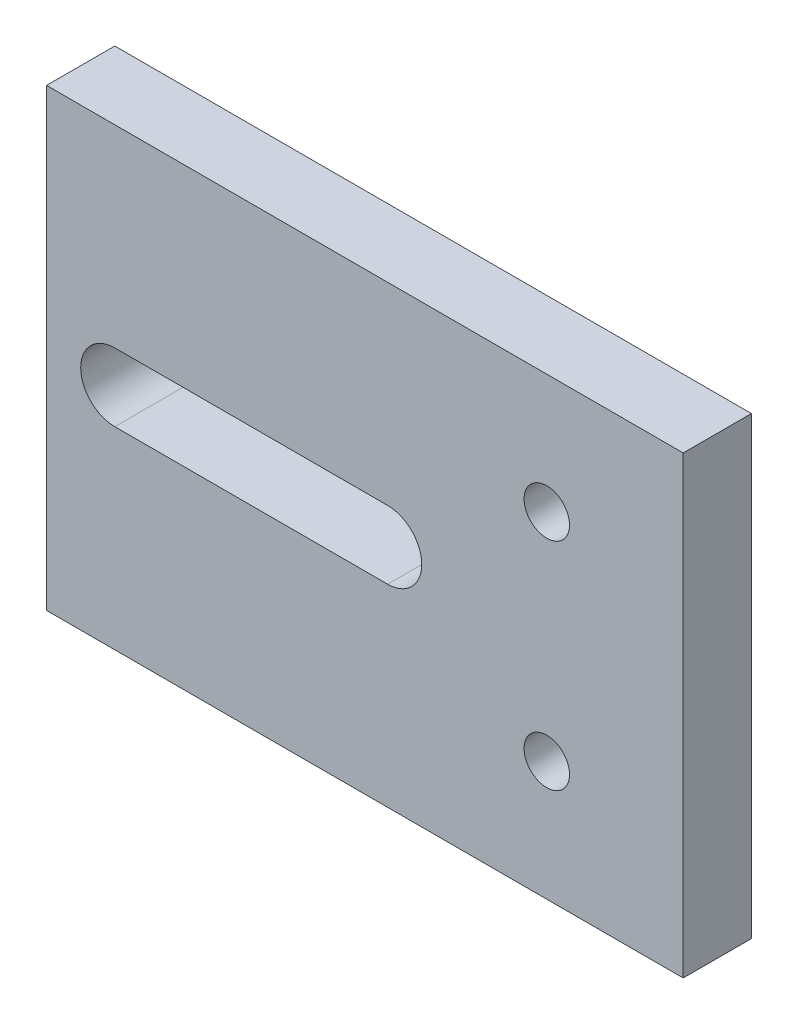
from build123d import *

# Parameters (mm, degrees)
SKETCH_1_W          = 28
SKETCH_1_H          = 20
SKETCH_1_R          = 1
EXTRUDE_1_DEPTH     = 3
CUT_EXTRUDE_1_DEPTH = 4
SKETCH_3_W          = 17.35128085
SKETCH_3_H          = 5.450829119
SKETCH_3_W_2        = 17.701224177
SKETCH_3_H_2        = 5.124932949
EXTRUDE_2_DEPTH     = 3


with BuildPart() as part:
    # 草图1 → 凸台-拉伸1 (new body)
    with BuildSketch(Plane.XY):
        Rectangle(SKETCH_1_W, SKETCH_1_H)
        with Locations((8, 4.75)):
            Circle(SKETCH_1_R, mode=Mode.SUBTRACT)
        with Locations((8, -4.75)):
            Circle(SKETCH_1_R, mode=Mode.SUBTRACT)
        with BuildLine():
            Line((-11, 6.25), (1, 6.25))
            ThreePointArc((1, 6.25), (2.5, 4.75), (1, 3.25))
            Line((1, 3.25), (-11, 3.25))
            ThreePointArc((-11, 3.25), (-12.5, 4.75), (-11, 6.25))
        make_face(mode=Mode.SUBTRACT)
        with BuildLine():
            Line((-11, -6.25), (1, -6.25))
            ThreePointArc((1, -6.25), (2.5, -4.75), (1, -3.25))
            Line((1, -3.25), (-11, -3.25))
            ThreePointArc((-11, -3.25), (-12.5, -4.75), (-11, -6.25))
        make_face(mode=Mode.SUBTRACT)
    extrude(amount=EXTRUDE_1_DEPTH)

    # 草图2 → 切除-拉伸1 (cut, through all)
    with BuildSketch(Plane.XY.offset(3)):
        with BuildLine():
            Line((1, -1.5), (-11, -1.5))
            ThreePointArc((-11, -1.5), (-12.5, 0), (-11, 1.5))
            Line((-11, 1.5), (1, 1.5))
            ThreePointArc((1, 1.5), (2.5, 0), (1, -1.5))
        make_face()
    extrude(amount=-CUT_EXTRUDE_1_DEPTH, mode=Mode.SUBTRACT)

    # 草图3 → 凸台-拉伸2 (add)
    with BuildSketch(Plane.XY.offset(3)):
        with Locations((-4.556899514, 5.212806564)):
            Rectangle(SKETCH_3_W, SKETCH_3_H)
        with Locations((-4.381927851, -5.15844561)):
            Rectangle(SKETCH_3_W_2, SKETCH_3_H_2)
    extrude(amount=-EXTRUDE_2_DEPTH)


solid = part.part
